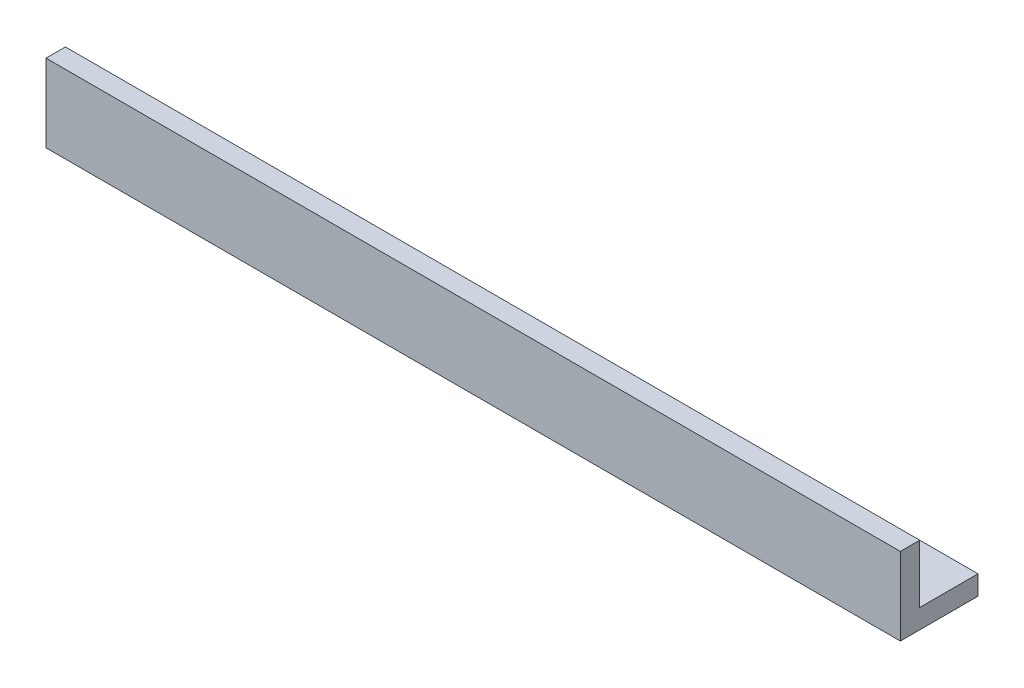
from build123d import *

# Parameters (mm, degrees)
SKETCH1_W           = 139.7
SKETCH1_H           = 12.7
BOSS_EXTRUDE1_DEPTH = 3.175
SKETCH7_W           = 139.7
SKETCH7_H           = 9.525
BOSS_EXTRUDE2_DEPTH = 3.175


with BuildPart() as part:
    # Sketch1 → Boss-Extrude1 (new body)
    with BuildSketch(Plane.XY):
        with Locations((1.936472643, 22.354273404)):
            Rectangle(SKETCH1_W, SKETCH1_H)
    extrude(amount=BOSS_EXTRUDE1_DEPTH)

    # Sketch7 → Boss-Extrude2 (add)
    with BuildSketch(Plane(origin=(0, 16.004273404, 0), x_dir=(-1, 0, 0), z_dir=(0, -1, 0))):
        with Locations((-1.936472643, 4.7625)):
            Rectangle(SKETCH7_W, SKETCH7_H)
    extrude(amount=-BOSS_EXTRUDE2_DEPTH)


solid = part.part
